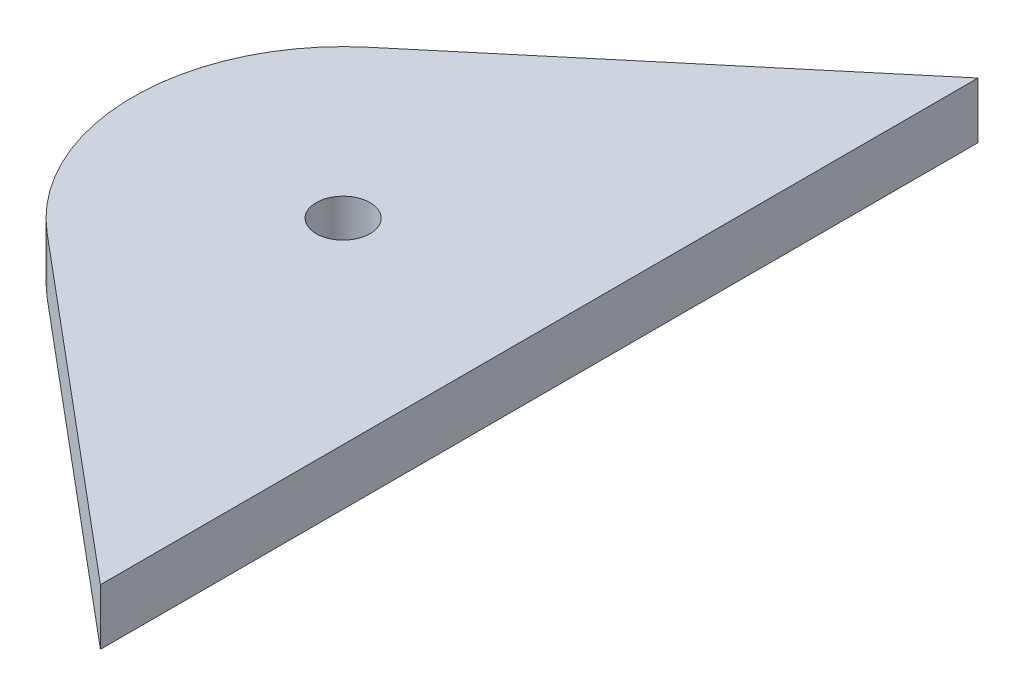
from build123d import *

# Parameters (mm, degrees)
SKETCH1_R           = 1.22148615
BOSS_EXTRUDE1_DEPTH = 2.54


with BuildPart() as part:
    # Sketch1 → Boss-Extrude1 (new body)
    with BuildSketch(Plane(origin=(0, 0, 0), x_dir=(1, 0, 0), z_dir=(0, 1, 0))):
        with BuildLine():
            Line((-444.533071271, -69.006399848), (-459.545623253, -81.603426679))
            ThreePointArc((-459.545623253, -81.603426679), (-462.948071271, -88.9), (-459.545623253, -96.196573321))
            Line((-459.545623253, -96.196573321), (-444.533071271, -108.793600152))
            Line((-444.533071271, -108.793600152), (-444.533071271, -69.006399848))
        make_face()
        with Locations((-453.423071271, -88.9)):
            Circle(SKETCH1_R, mode=Mode.SUBTRACT)
    extrude(amount=BOSS_EXTRUDE1_DEPTH)


solid = part.part
